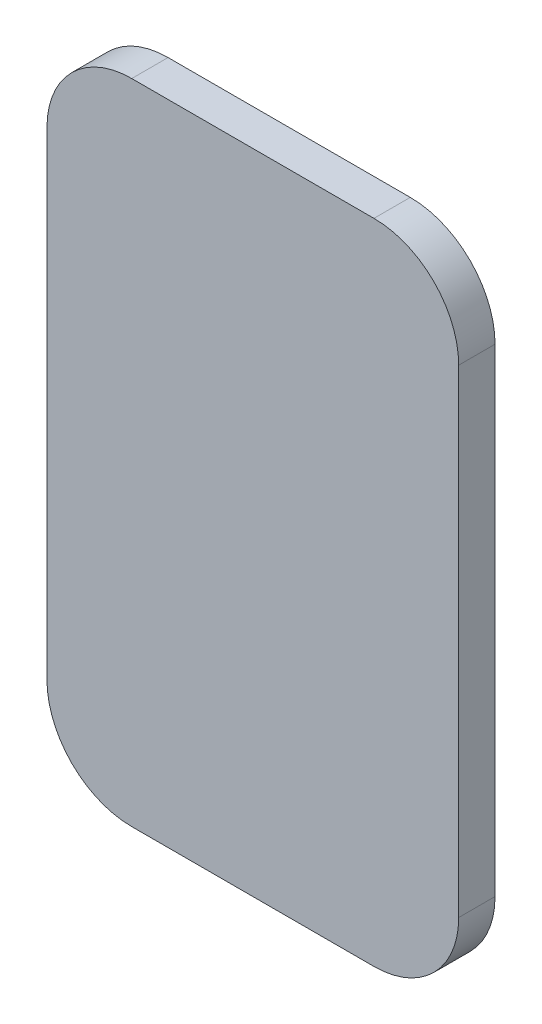
from build123d import *

# Parameters (mm, degrees)
BOSS_EXTRUDE1_DEPTH = 6


with BuildPart() as part:
    # Sketch1 → Boss-Extrude1 (new body)
    with BuildSketch(Plane.XY):
        with BuildLine():
            Line((-94.7, 58.985033023), (-94.7, -20.014966977))
            ThreePointArc((-94.7, -20.014966977), (-90.599494937, -29.914461914), (-80.7, -34.014966977))
            Line((-80.7, -34.014966977), (-40.7, -34.014966977))
            ThreePointArc((-40.7, -34.014966977), (-30.800505063, -29.914461914), (-26.7, -20.014966977))
            Line((-26.7, -20.014966977), (-26.7, 58.985033023))
            ThreePointArc((-26.7, 58.985033023), (-30.800505063, 68.88452796), (-40.7, 72.985033023))
            Line((-40.7, 72.985033023), (-80.7, 72.985033023))
            ThreePointArc((-80.7, 72.985033023), (-90.599494937, 68.88452796), (-94.7, 58.985033023))
        make_face()
    extrude(amount=BOSS_EXTRUDE1_DEPTH)


solid = part.part
